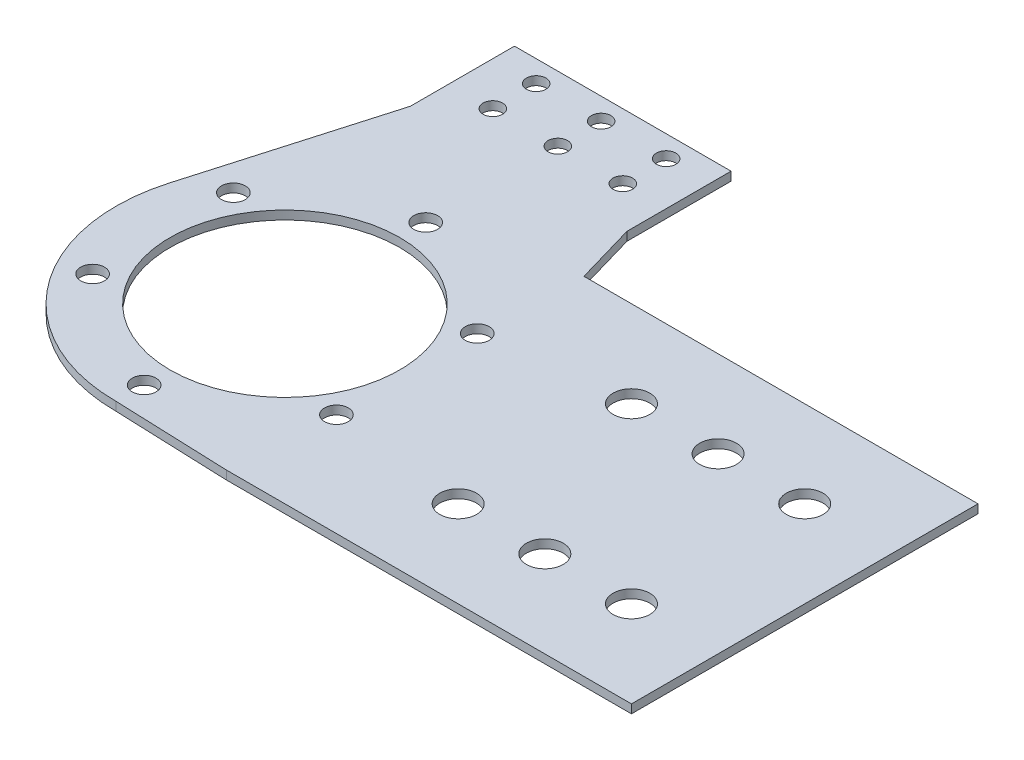
from build123d import *

# Parameters (mm, degrees)
SKETCH1_R            = 39
SKETCH1_R_2          = 26.5
BOSS_EXTRUDE1_DEPTH  = 1
SKETCH3_W            = 50
SKETCH3_H            = 51.5
BOSS_EXTRUDE2_DEPTH  = 1
BOSS_EXTRUDE3_DEPTH  = 1
BOSS_EXTRUDE5_DEPTH  = 1
SKETCH2_R            = 2.75
CUT_EXTRUDE1_DEPTH   = 2
CIRPATTERN1_COUNT    = 6
CUT_EXTRUDE2_START   = -3
SKETCH5_R            = 2.25
CUT_EXTRUDE2_DEPTH   = 4
LPATTERN1_COUNT      = 2
LPATTERN1_PITCH      = 15
LPATTERN1_COUNT_DIR2 = 2
LPATTERN1_PITCH_DIR2 = 10
LPATTERN2_COUNT      = 2
LPATTERN2_PITCH      = 15
LPATTERN2_COUNT_DIR2 = 2
LPATTERN2_PITCH_DIR2 = 10
CUT_EXTRUDE3_START   = -3
SKETCH8_R            = 4.25
CUT_EXTRUDE3_DEPTH   = 4
LPATTERN3_COUNT      = 3
LPATTERN3_PITCH      = 20


with BuildPart() as part:
    # Sketch1 → Boss-Extrude1 (new body, symmetric)
    with BuildSketch(Plane(origin=(0, 0, 0), x_dir=(1, 0, 0), z_dir=(0, 1, 0))):
        Circle(SKETCH1_R)
        Circle(SKETCH1_R_2, mode=Mode.SUBTRACT)
    extrude(amount=BOSS_EXTRUDE1_DEPTH, both=True)

    # Sketch3 → Boss-Extrude2 (add, symmetric)
    with BuildSketch(Plane(origin=(0, 0, 0), x_dir=(1, 0, 0), z_dir=(0, 1, 0))):
        with Locations((0, 52.25)):
            Rectangle(SKETCH3_W, SKETCH3_H)
    extrude(amount=BOSS_EXTRUDE2_DEPTH, both=True)

    # Sketch4 → Boss-Extrude3 (add, symmetric)
    with BuildSketch(Plane(origin=(0, 0, 0), x_dir=(1, 0, 0), z_dir=(0, 1, 0))):
        Polygon((-25, 53.966629547), (-37.466824315, 10.827607112), (-25, 29.933259094), align=None)
        Polygon((37.466824315, 10.827607112), (25, 29.933259094), (25, 53.966629547), align=None)
    extrude(amount=BOSS_EXTRUDE3_DEPTH, both=True)

    # Sketch7 → Boss-Extrude5 (add, symmetric)
    with BuildSketch(Plane(origin=(0, 0, 0), x_dir=(1, 0, 0), z_dir=(0, 1, 0))):
        Polygon((120, -40), (26.5, -40), (0, -39), (26.5, -15.728301656), (26.5, 0), (26.5, 40), (120, 40), align=None)
    extrude(amount=BOSS_EXTRUDE5_DEPTH, both=True)

    # Sketch2 → Cut-Extrude1 (cut, symmetric)
    with BuildSketch(Plane(origin=(0, 0, 0), x_dir=(1, 0, 0), z_dir=(0, 1, 0))):
        with Locations((0, 32.5)):
            Circle(SKETCH2_R)
    cut_extrude1 = extrude(amount=CUT_EXTRUDE1_DEPTH, both=True, mode=Mode.SUBTRACT)

    # CirPattern1: Cut-Extrude1 ×6 about axis
    cirpattern1_axis = Axis((0, 0, 0), (0, 1, 0))
    for i in range(1, CIRPATTERN1_COUNT):
        add(cut_extrude1.rotate(cirpattern1_axis, i * 360 / CIRPATTERN1_COUNT), mode=Mode.SUBTRACT)

    # Sketch5 → Cut-Extrude2 (cut)
    with BuildSketch(Plane(origin=(0, 1, 0), x_dir=(1, 0, 0), z_dir=(0, 1, 0)).offset(CUT_EXTRUDE2_START)):
        with Locations((0, 73)):
            Circle(SKETCH5_R)
    cut_extrude2 = extrude(amount=CUT_EXTRUDE2_DEPTH, mode=Mode.SUBTRACT)

    # LPattern1: Cut-Extrude2 2 × 2
    with Locations(*[(i * LPATTERN1_PITCH, 0, j * LPATTERN1_PITCH_DIR2) for i in range(LPATTERN1_COUNT) for j in range(LPATTERN1_COUNT_DIR2) if (i, j) != (0, 0)]):
        add(cut_extrude2, mode=Mode.SUBTRACT)

    # LPattern2: Cut-Extrude2 2 × 2
    with Locations(*[(-i * LPATTERN2_PITCH, 0, j * LPATTERN2_PITCH_DIR2) for i in range(LPATTERN2_COUNT) for j in range(LPATTERN2_COUNT_DIR2) if (i, j) != (0, 0)]):
        add(cut_extrude2, mode=Mode.SUBTRACT)

    # Sketch8 → Cut-Extrude3 (cut)
    with BuildSketch(Plane(origin=(0, 1, 0), x_dir=(1, 0, 0), z_dir=(0, 1, 0)).offset(CUT_EXTRUDE3_START)):
        with Locations((60, 20)):
            Circle(SKETCH8_R)
        with Locations((60, -20)):
            Circle(SKETCH8_R)
    cut_extrude3 = extrude(amount=CUT_EXTRUDE3_DEPTH, mode=Mode.SUBTRACT)

    # LPattern3: Cut-Extrude3 ×3
    with Locations(*[(i * LPATTERN3_PITCH, 0, 0) for i in range(1, LPATTERN3_COUNT)]):
        add(cut_extrude3, mode=Mode.SUBTRACT)


solid = part.part
